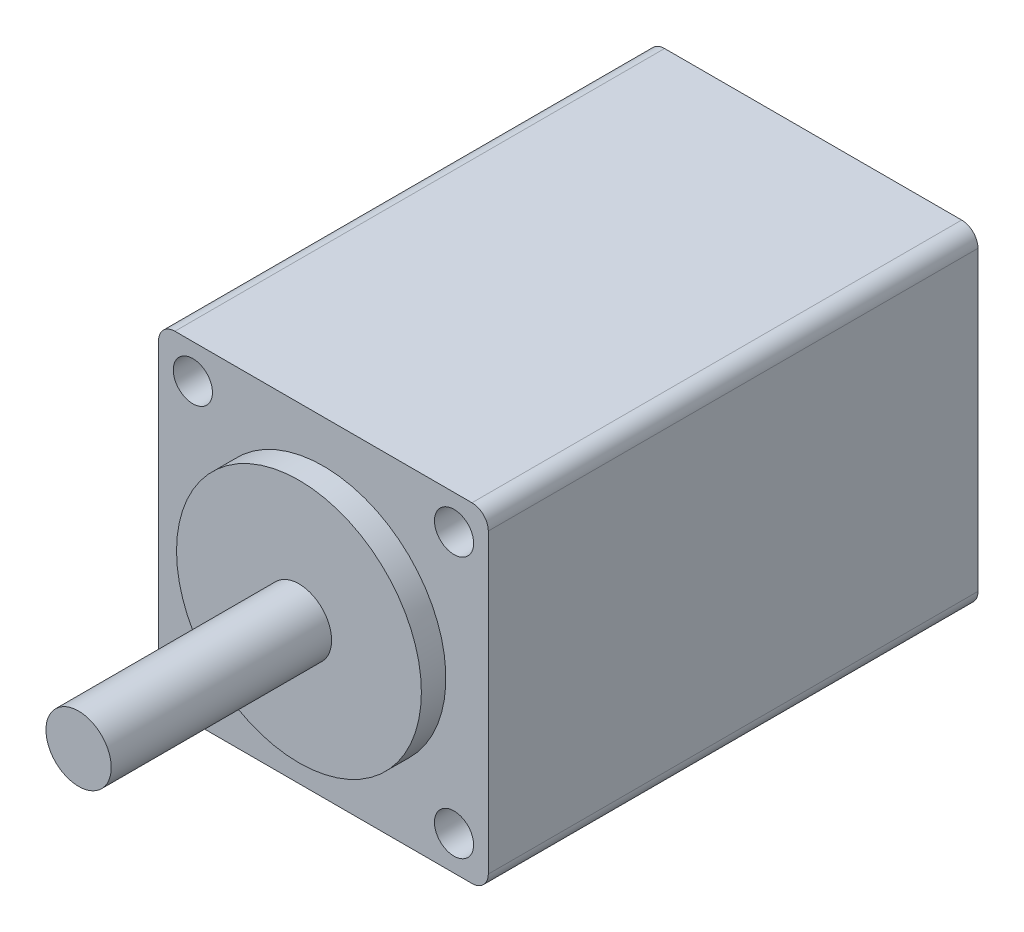
from build123d import *

# Parameters (mm, degrees)
ESQUISSE1_W             = 20.2
ESQUISSE1_H             = 20.2
BOSS_EXTRU_1_DEPTH      = 30
ESQUISSE2_R             = 7.5
BOSS_EXTRU_2_DEPTH      = 1.5
ESQUISSE3_R             = 2
BOSS_EXTRU_4_DEPTH      = 13.5
ESQUISSE4_R             = 1.2
ENL_V_MAT_EXTRU_1_DEPTH = 3.5
CONG_1_R                = 1


with BuildPart() as part:
    # Esquisse1 → Boss.-Extru.1 (new body)
    with BuildSketch(Plane.XY):
        Rectangle(ESQUISSE1_W, ESQUISSE1_H)
    extrude(amount=-BOSS_EXTRU_1_DEPTH)

    # Esquisse2 → Boss.-Extru.2 (add)
    with BuildSketch(Plane.XY):
        Circle(ESQUISSE2_R)
    extrude(amount=BOSS_EXTRU_2_DEPTH)

    # Esquisse3 → Boss.-Extru.4 (add)
    with BuildSketch(Plane.XY.offset(1.5)):
        Circle(ESQUISSE3_R)
    extrude(amount=BOSS_EXTRU_4_DEPTH)

    # Esquisse4 → Enlèv. mat.-Extru.1 (cut)
    with BuildSketch(Plane.XY):
        with Locations((-8, 8)):
            Circle(ESQUISSE4_R)
        with Locations((8, 8)):
            Circle(ESQUISSE4_R)
        with Locations((8, -8)):
            Circle(ESQUISSE4_R)
        with Locations((-8, -8)):
            Circle(ESQUISSE4_R)
    extrude(amount=-ENL_V_MAT_EXTRU_1_DEPTH, mode=Mode.SUBTRACT)

    # Congé1
    cong_1_edges = [part.edges().sort_by_distance(p)[0] for p in [
        (-10.1, 10.1, -15),
        (10.1, 10.1, -15),
        (10.1, -10.1, -15),
        (-10.1, -10.1, -15),
    ]]
    fillet(cong_1_edges, radius=CONG_1_R)


solid = part.part
